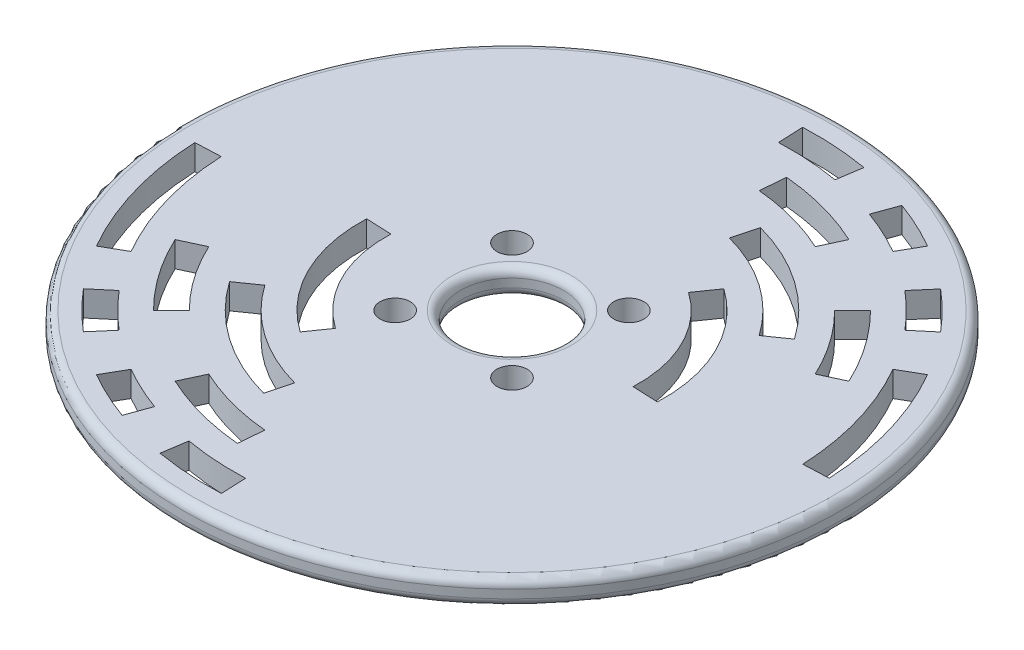
from build123d import *

# Parameters (mm, degrees)
SKETCH4_R           = 39
BOSS_EXTRUDE1_DEPTH = 3
CUT_EXTRUDE1_DEPTH  = 3
SKETCH1_R           = 6.096
SKETCH1_R_2         = 1.7859375
CUT_EXTRUDE3_DEPTH  = 3
FILLET1_R           = 1


with BuildPart() as part:
    # Sketch4 → Boss-Extrude1 (new body)
    with BuildSketch(Plane(origin=(0, 0, 0), x_dir=(1, 0, 0), z_dir=(0, 1, 0))):
        Circle(SKETCH4_R)
    extrude(amount=BOSS_EXTRUDE1_DEPTH)

    # Sketch3 → Cut-Extrude1 (cut)
    with BuildSketch(Plane(origin=(0, 0, 0), x_dir=(1, 0, 0), z_dir=(0, 1, 0))):
        with BuildLine():
            Line((32.968591312, 1.439439783), (35.965735977, 1.570297945))
            ThreePointArc((35.965735977, 1.570297945), (34.561794758, 10.073844505), (31.176914536, 18))
            Line((31.176914536, 18), (28.578838325, 16.5))
            ThreePointArc((28.578838325, 16.5), (31.681645195, 9.234357463), (32.968591312, 1.439439783))
        make_face()
        with BuildLine():
            Line((-1.570297945, 35.965735977), (-1.439439783, 32.968591312))
            ThreePointArc((-1.439439783, 32.968591312), (2.158303265, 32.929344467), (5.730389863, 32.498655849))
            Line((5.730389863, 32.498655849), (6.186823022, 35.464393705))
            ThreePointArc((6.186823022, 35.464393705), (2.321833751, 35.925048198), (-1.570297945, 35.965735977))
        make_face()
        with BuildLine():
            Line((12.31272516, 33.828934348), (11.28666473, 31.009856486))
            ThreePointArc((11.28666473, 31.009856486), (13.946402637, 29.908156972), (16.5, 28.578838325))
            Line((16.5, 28.578838325), (18, 31.176914536))
            ThreePointArc((18, 31.176914536), (15.214257423, 32.627080333), (12.31272516, 33.828934348))
        make_face()
        with BuildLine():
            Line((23.163459499, 27.558195587), (21.21199112, 25.279466623))
            ThreePointArc((21.21199112, 25.279466623), (23.334523779, 23.334523779), (25.279466623, 21.21199112))
            Line((25.279466623, 21.21199112), (27.577599952, 23.140353949))
            ThreePointArc((27.577599952, 23.140353949), (25.466509571, 25.445174203), (23.163459499, 27.558195587))
        make_face()
        with BuildLine():
            Line((14.985723324, -0.65429081), (17.982867988, -0.785148973))
            ThreePointArc((17.982867988, -0.785148973), (16.143709348, 7.961196424), (10.324375854, 14.744736797))
            Line((10.324375854, 14.744736797), (8.603646545, 12.287280664))
            ThreePointArc((8.603646545, 12.287280664), (13.453091123, 6.634330353), (14.985723324, -0.65429081))
        make_face()
        with BuildLine():
            Line((2.614672282, 29.885840943), (2.353205054, 26.897256848))
            ThreePointArc((2.353205054, 26.897256848), (6.988114218, 26.07999731), (11.410693067, 24.47031025))
            Line((11.410693067, 24.47031025), (12.678547852, 27.189233611))
            ThreePointArc((12.678547852, 27.189233611), (7.764571353, 28.977774789), (2.614672282, 29.885840943))
        make_face()
        with BuildLine():
            Line((21.213203436, 21.213203436), (19.091883092, 19.091883092))
            ThreePointArc((19.091883092, 19.091883092), (22.117105196, 15.486563781), (24.47031025, 11.410693067))
            Line((24.47031025, 11.410693067), (27.189233611, 12.678547852))
            ThreePointArc((27.189233611, 12.678547852), (24.574561329, 17.207293091), (21.213203436, 21.213203436))
        make_face()
        with BuildLine():
            Line((6.211657082, 23.182219831), (5.435199947, 20.284442352))
            ThreePointArc((5.435199947, 20.284442352), (12.045105163, 17.20219293), (17.20219293, 12.045105163))
            Line((17.20219293, 12.045105163), (19.659649063, 13.765834472))
            ThreePointArc((19.659649063, 13.765834472), (13.765834472, 19.659649063), (6.211657082, 23.182219831))
        make_face()
        with BuildLine():
            Line((-32.968591312, -1.439439783), (-35.965735977, -1.570297945))
            ThreePointArc((-35.965735977, -1.570297945), (-34.561794758, -10.073844505), (-31.176914536, -18))
            Line((-31.176914536, -18), (-28.578838325, -16.5))
            ThreePointArc((-28.578838325, -16.5), (-31.681645195, -9.234357463), (-32.968591312, -1.439439783))
        make_face()
        with BuildLine():
            Line((1.570297945, -35.965735977), (1.439439783, -32.968591312))
            ThreePointArc((1.439439783, -32.968591312), (-2.158303265, -32.929344467), (-5.730389863, -32.498655849))
            Line((-5.730389863, -32.498655849), (-6.186823022, -35.464393705))
            ThreePointArc((-6.186823022, -35.464393705), (-2.321833751, -35.925048198), (1.570297945, -35.965735977))
        make_face()
        with BuildLine():
            Line((-12.31272516, -33.828934348), (-11.28666473, -31.009856486))
            ThreePointArc((-11.28666473, -31.009856486), (-13.946402637, -29.908156972), (-16.5, -28.578838325))
            Line((-16.5, -28.578838325), (-18, -31.176914536))
            ThreePointArc((-18, -31.176914536), (-15.214257423, -32.627080333), (-12.31272516, -33.828934348))
        make_face()
        with BuildLine():
            Line((-23.163459499, -27.558195587), (-21.21199112, -25.279466623))
            ThreePointArc((-21.21199112, -25.279466623), (-23.334523779, -23.334523779), (-25.279466623, -21.21199112))
            Line((-25.279466623, -21.21199112), (-27.577599952, -23.140353949))
            ThreePointArc((-27.577599952, -23.140353949), (-25.466509571, -25.445174203), (-23.163459499, -27.558195587))
        make_face()
        with BuildLine():
            Line((-14.985723324, 0.65429081), (-17.982867988, 0.785148973))
            ThreePointArc((-17.982867988, 0.785148973), (-16.143709348, -7.961196424), (-10.324375854, -14.744736797))
            Line((-10.324375854, -14.744736797), (-8.603646545, -12.287280664))
            ThreePointArc((-8.603646545, -12.287280664), (-13.453091123, -6.634330353), (-14.985723324, 0.65429081))
        make_face()
        with BuildLine():
            Line((-2.614672282, -29.885840943), (-2.353205054, -26.897256848))
            ThreePointArc((-2.353205054, -26.897256848), (-6.988114218, -26.07999731), (-11.410693067, -24.47031025))
            Line((-11.410693067, -24.47031025), (-12.678547852, -27.189233611))
            ThreePointArc((-12.678547852, -27.189233611), (-7.764571353, -28.977774789), (-2.614672282, -29.885840943))
        make_face()
        with BuildLine():
            Line((-21.213203436, -21.213203436), (-19.091883092, -19.091883092))
            ThreePointArc((-19.091883092, -19.091883092), (-22.117105196, -15.486563781), (-24.47031025, -11.410693067))
            Line((-24.47031025, -11.410693067), (-27.189233611, -12.678547852))
            ThreePointArc((-27.189233611, -12.678547852), (-24.574561329, -17.207293091), (-21.213203436, -21.213203436))
        make_face()
        with BuildLine():
            Line((-6.211657082, -23.182219831), (-5.435199947, -20.284442352))
            ThreePointArc((-5.435199947, -20.284442352), (-12.045105163, -17.20219293), (-17.20219293, -12.045105163))
            Line((-17.20219293, -12.045105163), (-19.659649063, -13.765834472))
            ThreePointArc((-19.659649063, -13.765834472), (-13.765834472, -19.659649063), (-6.211657082, -23.182219831))
        make_face()
    extrude(amount=CUT_EXTRUDE1_DEPTH, mode=Mode.SUBTRACT)

    # Sketch1 → Cut-Extrude3 (cut)
    with BuildSketch(Plane(origin=(0, 0, 0), x_dir=(1, 0, 0), z_dir=(0, 1, 0))):
        Circle(SKETCH1_R)
        with Locations((6.914797213, 6.914797213)):
            Circle(SKETCH1_R_2)
        with Locations((6.914797213, -6.914797213)):
            Circle(SKETCH1_R_2)
        with Locations((-6.914797213, -6.914797213)):
            Circle(SKETCH1_R_2)
        with Locations((-6.914797213, 6.914797213)):
            Circle(SKETCH1_R_2)
    extrude(amount=CUT_EXTRUDE3_DEPTH, mode=Mode.SUBTRACT)

    # Fillet1
    fillet1_edges = [part.edges().sort_by_distance(p)[0] for p in [
        (-39, 0, 0),
        (-6.096, 0, 0),
        (-6.096, 3, 0),
        (-39, 3, 0),
    ]]
    fillet(fillet1_edges, radius=FILLET1_R)


solid = part.part
